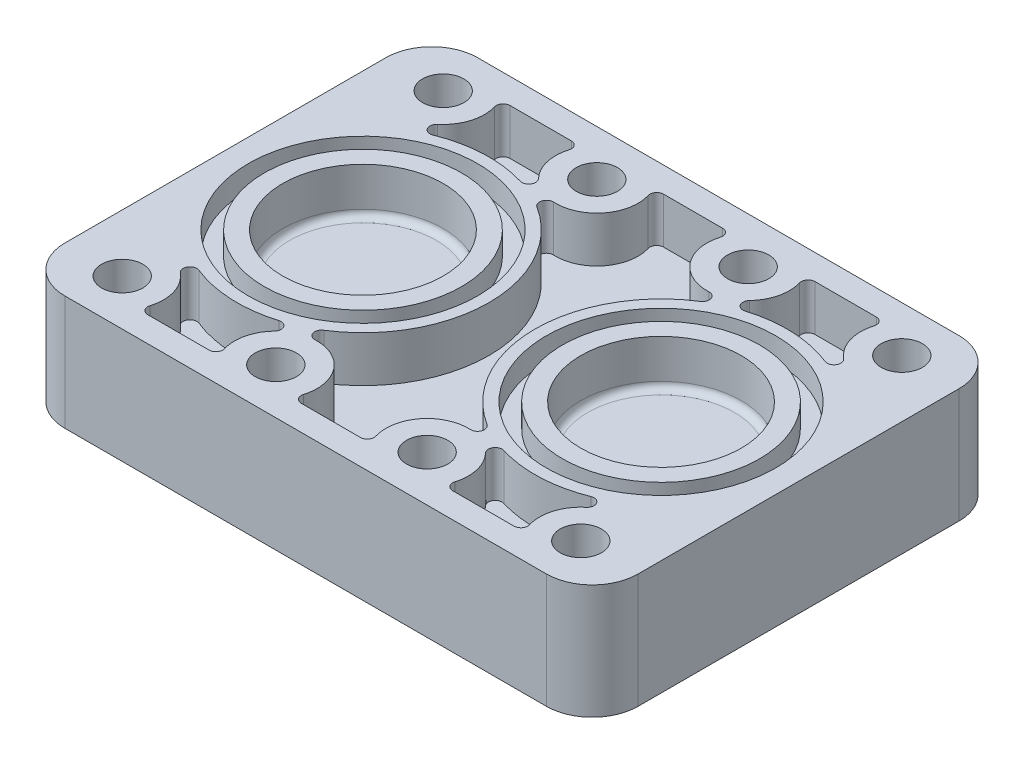
from build123d import *

# Parameters (mm, degrees)
BOSS_EXTRUDE1_DEPTH = 50
SKETCH2_R           = 9
CUT_EXTRUDE1_DEPTH  = 50
SKETCH4_R           = 12.5
CUT_EXTRUDE2_DEPTH  = 35
SKETCH7_R           = 35
CUT_EXTRUDE3_DEPTH  = 20
FILLET1_R           = 3
SKETCH8_R           = 50
SKETCH8_R_2         = 43
CUT_EXTRUDE4_DEPTH  = 10
CUT_EXTRUDE5_DEPTH  = 20


with BuildPart() as part:
    # Sketch1 → Boss-Extrude1 (new body)
    with BuildSketch(Plane(origin=(0, 0, 0), x_dir=(1, 0, 0), z_dir=(0, 1, 0))):
        with BuildLine():
            Line((-105, -90), (105, -90))
            ThreePointArc((105, -90), (119.142135624, -84.142135624), (125, -70))
            Line((125, -70), (125, 70))
            ThreePointArc((125, 70), (119.142135624, 84.142135624), (105, 90))
            Line((105, 90), (-105, 90))
            ThreePointArc((-105, 90), (-119.142135624, 84.142135624), (-125, 70))
            Line((-125, 70), (-125, -70))
            ThreePointArc((-125, -70), (-119.142135624, -84.142135624), (-105, -90))
        make_face()
    extrude(amount=BOSS_EXTRUDE1_DEPTH)

    # Sketch2 → Cut-Extrude1 (cut)
    with BuildSketch(Plane(origin=(0, 50, 0), x_dir=(1, 0, 0), z_dir=(0, 1, 0))):
        with Locations((-100, -70)):
            Circle(SKETCH2_R)
        with Locations((-33, -70)):
            Circle(SKETCH2_R)
        with Locations((33, -70)):
            Circle(SKETCH2_R)
        with Locations((100, -70)):
            Circle(SKETCH2_R)
        with Locations((100, 70)):
            Circle(SKETCH2_R)
        with Locations((33, 70)):
            Circle(SKETCH2_R)
        with Locations((-33, 70)):
            Circle(SKETCH2_R)
        with Locations((-100, 70)):
            Circle(SKETCH2_R)
    extrude(amount=-CUT_EXTRUDE1_DEPTH, mode=Mode.SUBTRACT)

    # Sketch4 → Cut-Extrude2 (cut)
    with BuildSketch(Plane(origin=(0, 35, 0), x_dir=(1, 0, 0), z_dir=(0, 1, 0))):
        with Locations((-100, -70)):
            Circle(SKETCH4_R)
        with Locations((-33, -70)):
            Circle(SKETCH4_R)
        with Locations((33, -70)):
            Circle(SKETCH4_R)
        with Locations((100, -70)):
            Circle(SKETCH4_R)
        with Locations((100, 70)):
            Circle(SKETCH4_R)
        with Locations((33, 70)):
            Circle(SKETCH4_R)
        with Locations((-33, 70)):
            Circle(SKETCH4_R)
        with Locations((-100, 70)):
            Circle(SKETCH4_R)
    extrude(amount=-CUT_EXTRUDE2_DEPTH, mode=Mode.SUBTRACT)

    # Sketch7 → Cut-Extrude3 (cut)
    with BuildSketch(Plane(origin=(0, 50, 0), x_dir=(1, 0, 0), z_dir=(0, 1, 0))):
        with Locations((-65, 0)):
            Circle(SKETCH7_R)
        with Locations((65, 0)):
            Circle(SKETCH7_R)
    extrude(amount=-CUT_EXTRUDE3_DEPTH, mode=Mode.SUBTRACT)

    # Fillet1
    fillet1_edges = [part.edges().sort_by_distance(p)[0] for p in [
        (-100, 30, 0),
        (30, 30, 0),
    ]]
    fillet(fillet1_edges, radius=FILLET1_R)

    # Sketch8 → Cut-Extrude4 (cut)
    with BuildSketch(Plane(origin=(0, 50, 0), x_dir=(1, 0, 0), z_dir=(0, 1, 0))):
        with Locations((-65, 0)):
            Circle(SKETCH8_R)
        with Locations((-65, 0)):
            Circle(SKETCH8_R_2, mode=Mode.SUBTRACT)
        with Locations((65, 0)):
            Circle(SKETCH8_R)
        with Locations((65, 0)):
            Circle(SKETCH8_R_2, mode=Mode.SUBTRACT)
    extrude(amount=-CUT_EXTRUDE4_DEPTH, mode=Mode.SUBTRACT)

    # Sketch9 → Cut-Extrude5 (cut)
    with BuildSketch(Plane(origin=(0, 50, 0), x_dir=(1, 0, 0), z_dir=(0, 1, 0))):
        with BuildLine():
            Line((-53.124611797, -79), (-79.875388203, -79))
            ThreePointArc((-79.875388203, -79), (-82.28073938, -77.792842914), (-82.750332745, -75.142857143))
            ThreePointArc((-82.750332745, -75.142857143), (-82.776149203, -64.771332509), (-88.520347372, -56.135744681))
            ThreePointArc((-88.520347372, -56.135744681), (-89.185331801, -52.291224502), (-85.489464765, -51.040981903))
            ThreePointArc((-85.489464765, -51.040981903), (-67.418125523, -54.946816732), (-49.07353502, -52.643591379))
            ThreePointArc((-49.07353502, -52.643591379), (-45.649930196, -53.942627335), (-46.032701785, -57.584337142))
            ThreePointArc((-46.032701785, -57.584337142), (-50.502310556, -65.796534146), (-50.249667255, -75.142857143))
            ThreePointArc((-50.249667255, -75.142857143), (-50.71926062, -77.792842914), (-53.124611797, -79))
        make_face()
        with BuildLine():
            Line((53.124611797, 79), (79.875388203, 79))
            ThreePointArc((79.875388203, 79), (82.28073938, 77.792842914), (82.750332745, 75.142857143))
            ThreePointArc((82.750332745, 75.142857143), (82.776149203, 64.771332509), (88.520347372, 56.135744681))
            ThreePointArc((88.520347372, 56.135744681), (89.185331801, 52.291224502), (85.489464765, 51.040981903))
            ThreePointArc((85.489464765, 51.040981903), (67.418125523, 54.946816732), (49.07353502, 52.643591379))
            ThreePointArc((49.07353502, 52.643591379), (45.649930196, 53.942627335), (46.032701785, 57.584337142))
            ThreePointArc((46.032701785, 57.584337142), (50.502310556, 65.796534146), (50.249667255, 75.142857143))
            ThreePointArc((50.249667255, 75.142857143), (50.71926062, 77.792842914), (53.124611797, 79))
        make_face()
        with BuildLine():
            Line((-53.124611797, 79), (-79.875388203, 79))
            ThreePointArc((-79.875388203, 79), (-82.28073938, 77.792842914), (-82.750332745, 75.142857143))
            ThreePointArc((-82.750332745, 75.142857143), (-82.776149203, 64.771332509), (-88.520347372, 56.135744681))
            ThreePointArc((-88.520347372, 56.135744681), (-89.185331801, 52.291224502), (-85.489464765, 51.040981903))
            ThreePointArc((-85.489464765, 51.040981903), (-67.418125523, 54.946816732), (-49.07353502, 52.643591379))
            ThreePointArc((-49.07353502, 52.643591379), (-45.649930196, 53.942627335), (-46.032701785, 57.584337142))
            ThreePointArc((-46.032701785, 57.584337142), (-50.502310556, 65.796534146), (-50.249667255, 75.142857143))
            ThreePointArc((-50.249667255, 75.142857143), (-50.71926062, 77.792842914), (-53.124611797, 79))
        make_face()
        with BuildLine():
            Line((-12.875388203, -79), (12.875388203, -79))
            ThreePointArc((12.875388203, -79), (15.28073938, -77.792842914), (15.750332745, -75.142857143))
            ThreePointArc((15.750332745, -75.142857143), (18.829727241, -58.900298656), (33.862156902, -52.020659482))
            ThreePointArc((33.862156902, -52.020659482), (36.866627296, -49.927403152), (35.608995423, -46.488373277))
            ThreePointArc((35.608995423, -46.488373277), (10, 0), (35.608995423, 46.488373277))
            ThreePointArc((35.608995423, 46.488373277), (36.866627296, 49.927403152), (33.862156902, 52.020659482))
            ThreePointArc((33.862156902, 52.020659482), (18.829727241, 58.900298656), (15.750332745, 75.142857143))
            ThreePointArc((15.750332745, 75.142857143), (15.28073938, 77.792842914), (12.875388203, 79))
            Line((12.875388203, 79), (-12.875388203, 79))
            ThreePointArc((-12.875388203, 79), (-15.28073938, 77.792842914), (-15.750332745, 75.142857143))
            ThreePointArc((-15.750332745, 75.142857143), (-18.829727241, 58.900298656), (-33.862156902, 52.020659482))
            ThreePointArc((-33.862156902, 52.020659482), (-36.866627296, 49.927403152), (-35.608995423, 46.488373277))
            ThreePointArc((-35.608995423, 46.488373277), (-10, 0), (-35.608995423, -46.488373277))
            ThreePointArc((-35.608995423, -46.488373277), (-36.866627296, -49.927403152), (-33.862156902, -52.020659482))
            ThreePointArc((-33.862156902, -52.020659482), (-18.829727241, -58.900298656), (-15.750332745, -75.142857143))
            ThreePointArc((-15.750332745, -75.142857143), (-15.28073938, -77.792842914), (-12.875388203, -79))
        make_face()
        with BuildLine():
            Line((53.124611797, -79), (79.875388203, -79))
            ThreePointArc((79.875388203, -79), (82.28073938, -77.792842914), (82.750332745, -75.142857143))
            ThreePointArc((82.750332745, -75.142857143), (82.776149203, -64.771332509), (88.520347372, -56.135744681))
            ThreePointArc((88.520347372, -56.135744681), (89.185331801, -52.291224502), (85.489464765, -51.040981903))
            ThreePointArc((85.489464765, -51.040981903), (67.418125523, -54.946816732), (49.07353502, -52.643591379))
            ThreePointArc((49.07353502, -52.643591379), (45.649930196, -53.942627335), (46.032701785, -57.584337142))
            ThreePointArc((46.032701785, -57.584337142), (50.502310556, -65.796534146), (50.249667255, -75.142857143))
            ThreePointArc((50.249667255, -75.142857143), (50.71926062, -77.792842914), (53.124611797, -79))
        make_face()
    extrude(amount=-CUT_EXTRUDE5_DEPTH, mode=Mode.SUBTRACT)


solid = part.part
